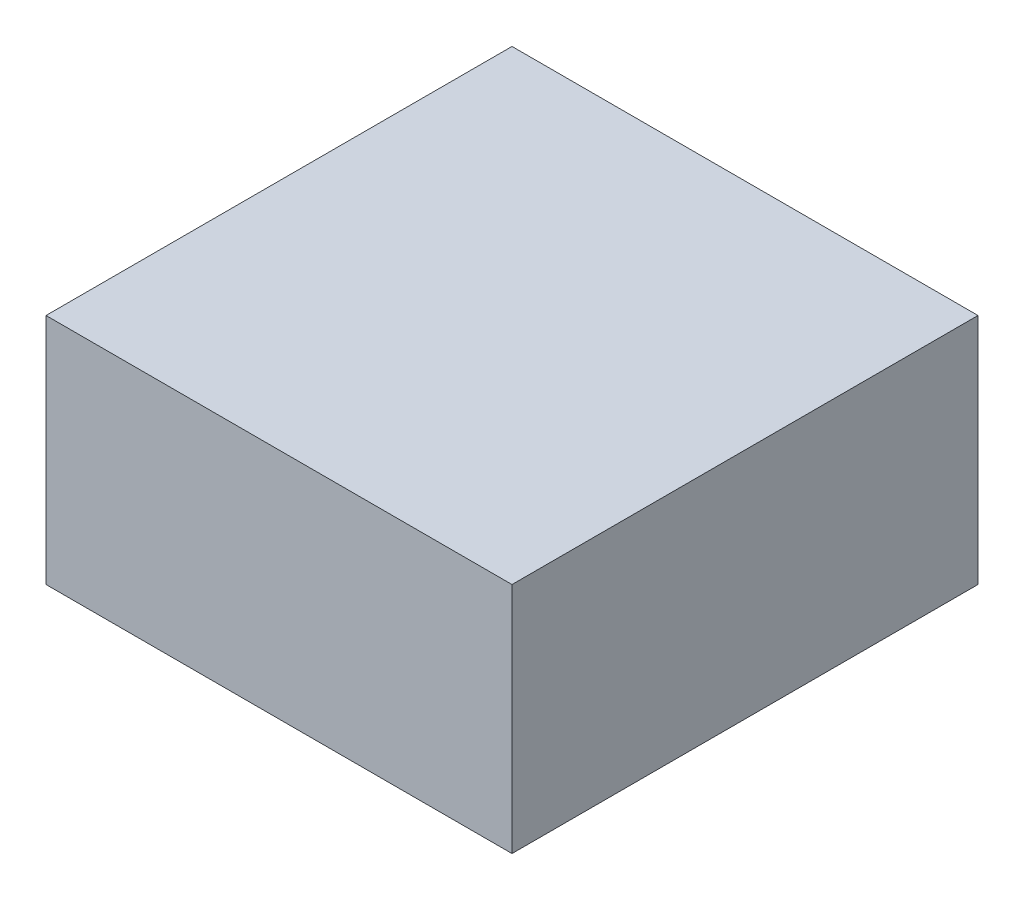
from build123d import *

# Parameters (mm, degrees)
SKETCH1_W           = 40
SKETCH1_H           = 20
BOSS_EXTRUDE1_DEPTH = 40


with BuildPart() as part:
    # Sketch1 → Boss-Extrude1 (new body)
    with BuildSketch(Plane.XY):
        Rectangle(SKETCH1_W, SKETCH1_H)
    extrude(amount=BOSS_EXTRUDE1_DEPTH)


solid = part.part
